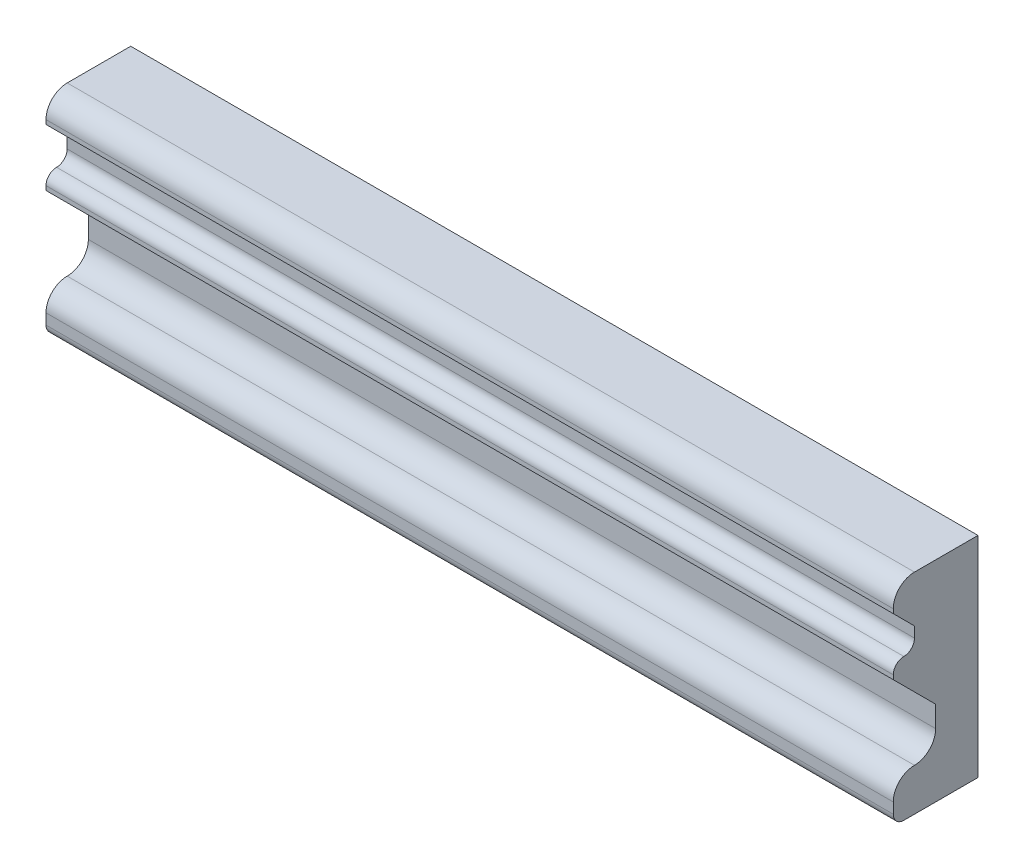
from build123d import *

# Parameters (mm, degrees)
SALIENTE_EXTRUIR1_DEPTH = 400


with BuildPart() as part:
    # Croquis1 → Saliente-Extruir1 (new body)
    with BuildSketch(Plane(origin=(0, 0, 0), x_dir=(0, 0, -1), z_dir=(1, 0, 0))):
        with BuildLine():
            Line((-20, 37.5), (-20, 39.5))
            ThreePointArc((-20, 39.5), (-17.071067812, 46.571067812), (-10, 49.5))
            Line((-10, 49.5), (20, 49.5))
            Line((20, 49.5), (20, -49.5))
            Line((20, -49.5), (-15, -49.5))
            ThreePointArc((-15, -49.5), (-18.535533906, -48.035533906), (-20, -44.5))
            Line((-20, -44.5), (-20, -39.5))
            ThreePointArc((-20, -39.5), (-17.071067812, -32.428932188), (-10, -29.5))
            ThreePointArc((-10, -29.5), (-2.928932188, -26.571067812), (0, -19.5))
            Line((0, -19.5), (0, -9.5))
            Line((0, -9.5), (-20, 10.5))
            Line((-20, 10.5), (-20, 12.5))
            ThreePointArc((-20, 12.5), (-18.535533906, 16.035533906), (-15, 17.5))
            ThreePointArc((-15, 17.5), (-11.464466094, 18.964466094), (-10, 22.5))
            Line((-10, 22.5), (-10, 27.5))
            Line((-10, 27.5), (-20, 37.5))
        make_face()
    extrude(amount=SALIENTE_EXTRUIR1_DEPTH)


solid = part.part
